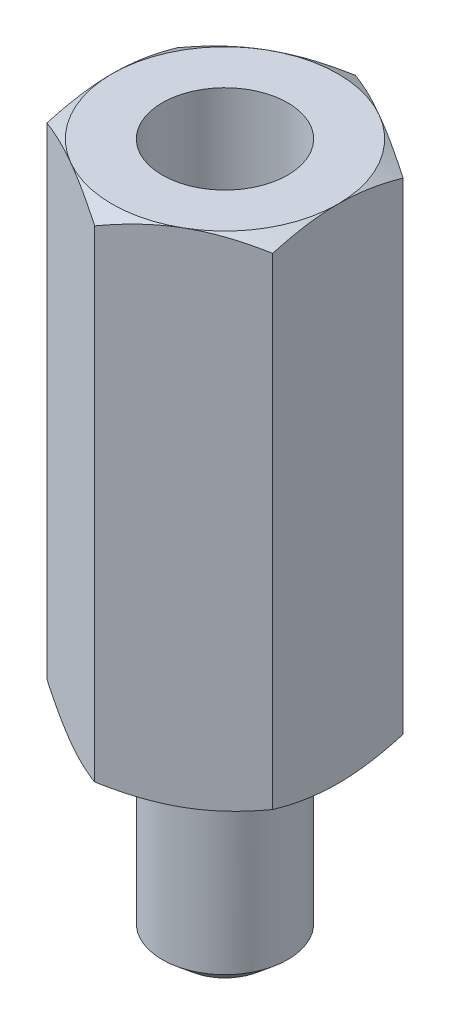
from build123d import *

# Parameters (mm, degrees)
BOSS_EXTRUDE1_DEPTH = 10
SKETCH2_OUTSIDE_W   = 47.032
SKETCH2_OUTSIDE_H   = 47.728
SKETCH2_OUTSIDE_R   = 2.25
CUT_EXTRUDE1_DEPTH  = 11
CUT_EXTRUDE1_TAPER  = 60
SKETCH3_OUTSIDE_W   = 47.032
SKETCH3_OUTSIDE_H   = 47.728
SKETCH3_OUTSIDE_R   = 2.25
CUT_EXTRUDE2_DEPTH  = 11
CUT_EXTRUDE2_TAPER  = 60
SKETCH4_R           = 1.25
CUT_EXTRUDE3_DEPTH  = 4.8
SKETCH5_R           = 1.25
BOSS_EXTRUDE2_DEPTH = 3.9
CHAMFER1_SIZE       = 0.36
CHAMFER1_SIZE2      = 0.429031293


with BuildPart() as part:
    # Sketch1 → Boss-Extrude1 (new body)
    with BuildSketch(Plane(origin=(0, 0, 0), x_dir=(1, 0, 0), z_dir=(0, 1, 0))):
        Polygon((0, 2.598076211), (-2.25, 1.299038106), (-2.25, -1.299038106), (0, -2.598076211), (2.25, -1.299038106), (2.25, 1.299038106), align=None)
    extrude(amount=BOSS_EXTRUDE1_DEPTH)

    # Sketch2 outside → Cut-Extrude1 (cut, through all)
    with BuildSketch(Plane(origin=(0, 10, 0), x_dir=(1, 0, 0), z_dir=(0, 1, 0))):
        Rectangle(SKETCH2_OUTSIDE_W, SKETCH2_OUTSIDE_H)
        Circle(SKETCH2_OUTSIDE_R, mode=Mode.SUBTRACT)
    extrude(amount=-CUT_EXTRUDE1_DEPTH, taper=CUT_EXTRUDE1_TAPER, mode=Mode.SUBTRACT)

    # Sketch3 outside → Cut-Extrude2 (cut, through all)
    with BuildSketch(Plane.XZ):
        Rectangle(SKETCH3_OUTSIDE_W, SKETCH3_OUTSIDE_H)
        Circle(SKETCH3_OUTSIDE_R, mode=Mode.SUBTRACT)
    extrude(amount=-CUT_EXTRUDE2_DEPTH, taper=CUT_EXTRUDE2_TAPER, mode=Mode.SUBTRACT)

    # Sketch4 → Cut-Extrude3 (cut)
    with BuildSketch(Plane(origin=(0, 10, 0), x_dir=(1, 0, 0), z_dir=(0, 1, 0))):
        Circle(SKETCH4_R)
    extrude(amount=-CUT_EXTRUDE3_DEPTH, mode=Mode.SUBTRACT)

    # Sketch5 → Boss-Extrude2 (add)
    with BuildSketch(Plane.XZ):
        Circle(SKETCH5_R)
    extrude(amount=BOSS_EXTRUDE2_DEPTH)

    # Chamfer1
    chamfer1_edges = [part.edges().sort_by_distance(p)[0] for p in [
        (-1.25, -3.9, 0),
    ]]
    chamfer1_side = [part.faces().sort_by_distance(p)[0] for p in [
        (-1.25, -1.95, 0),
    ]]
    chamfer(chamfer1_edges, length=CHAMFER1_SIZE, length2=CHAMFER1_SIZE2, reference=chamfer1_side[0])


solid = part.part
